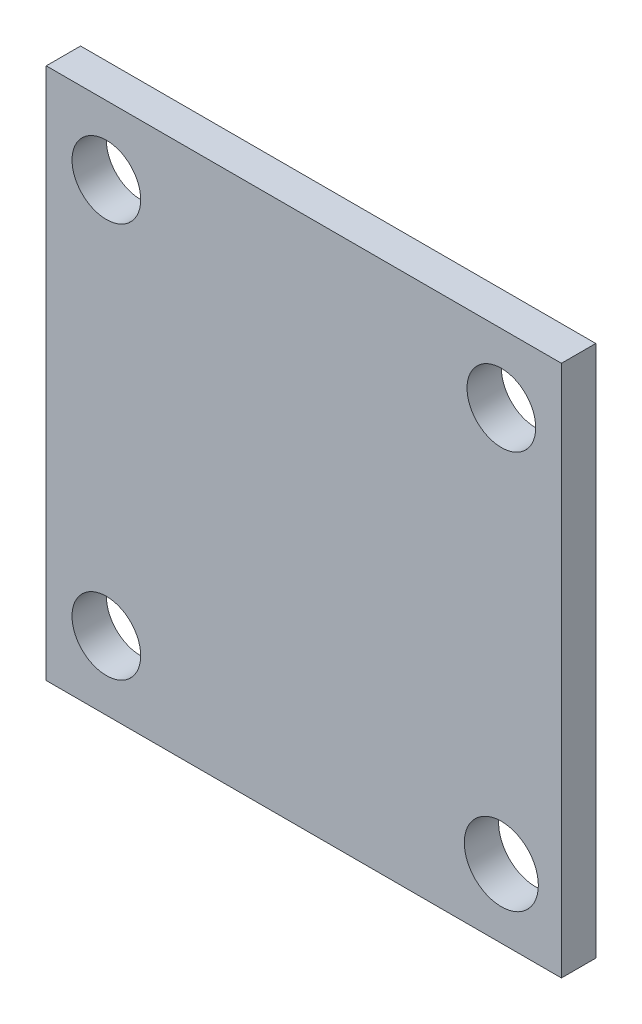
from build123d import *

# Parameters (mm, degrees)
SKETCH2_W           = 30.002183488
SKETCH2_H           = 31.002183488
SKETCH2_R           = 2
SKETCH2_R_2         = 2.156266898
BOSS_EXTRUDE1_DEPTH = 2


with BuildPart() as part:
    # Sketch2 → Boss-Extrude1 (new body)
    with BuildSketch(Plane.XY):
        Rectangle(SKETCH2_W, SKETCH2_H)
        with Locations((-11.498908256, 11.503275233)):
            Circle(SKETCH2_R, mode=Mode.SUBTRACT)
        with Locations((11.503275233, 11.501091744)):
            Circle(SKETCH2_R, mode=Mode.SUBTRACT)
        with Locations((-11.501091744, -11.498908256)):
            Circle(SKETCH2_R, mode=Mode.SUBTRACT)
        with Locations((11.501091744, -11.501091744)):
            Circle(SKETCH2_R_2, mode=Mode.SUBTRACT)
    extrude(amount=BOSS_EXTRUDE1_DEPTH)


solid = part.part
